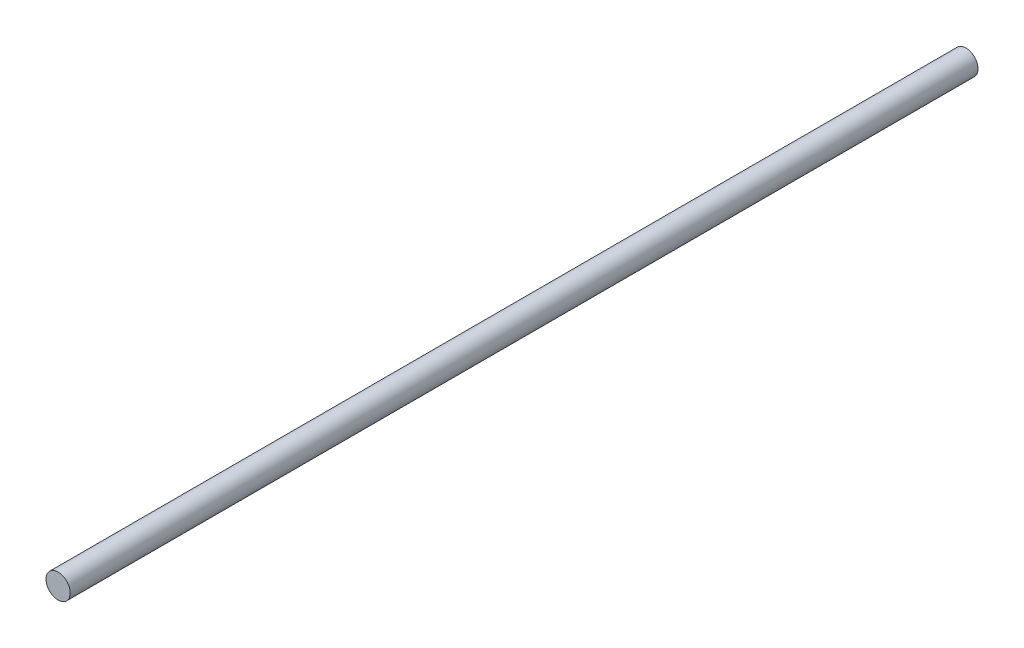
from build123d import *

# Parameters (mm, degrees)
SKETCH_1_R      = 4
EXTRUDE_1_DEPTH = 300


with BuildPart() as part:
    # 草图1 → 凸台-拉伸1 (new body)
    with BuildSketch(Plane.XY):
        Circle(SKETCH_1_R)
    extrude(amount=EXTRUDE_1_DEPTH)


solid = part.part
